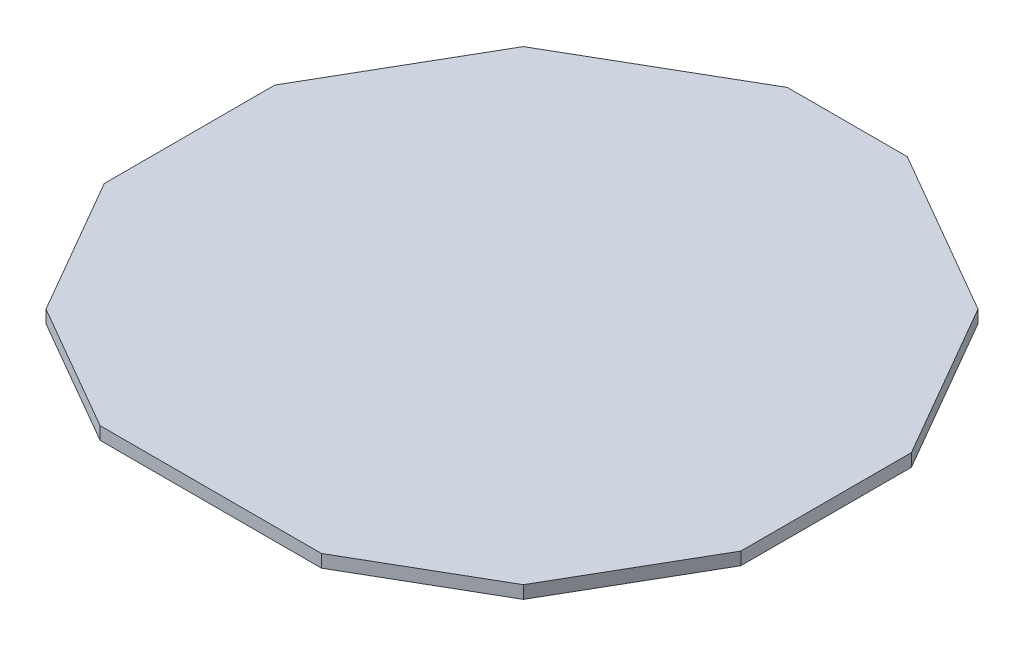
from build123d import *

# Parameters (mm, degrees)
AUFSATZ_LINEAR_AUSTRAGEN1_DEPTH = 1


with BuildPart() as part:
    # Skizze1 → Aufsatz-Linear austragen1 (new body)
    with BuildSketch(Plane(origin=(0, 0, 0), x_dir=(1, 0, 0), z_dir=(0, 1, 0))):
        Polygon((4.70514244, 30), (-4.70514244, 30), (-17.854688202, 22.408106214), (-25, 10.032063144), (-25, -3.365396477), (-18.747852177, -14.194434164), (-8.692317182, -20), (8.692317182, -20), (18.747852177, -14.194434164), (25, -3.365396477), (25, 10.032063144), (17.854688202, 22.408106214), align=None)
    extrude(amount=AUFSATZ_LINEAR_AUSTRAGEN1_DEPTH)


solid = part.part
